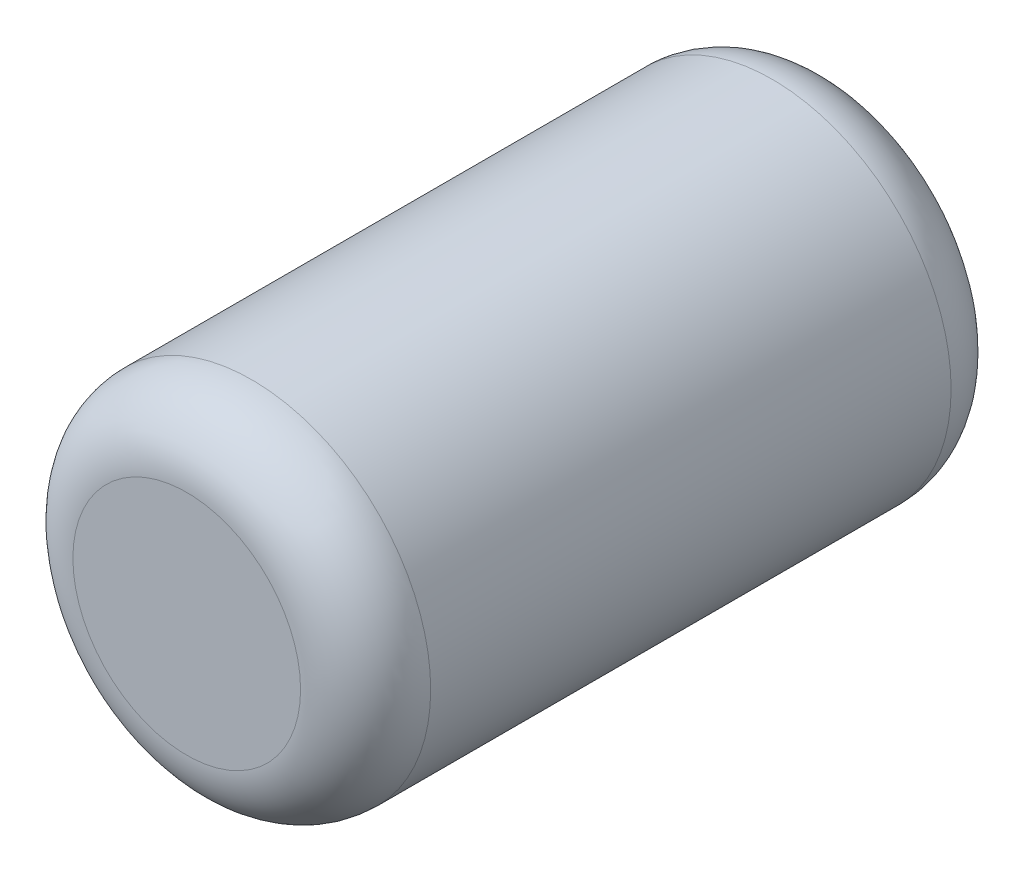
from build123d import *

# Parameters (mm, degrees)
SKETCH1_R           = 34.925
BOSS_EXTRUDE1_DEPTH = 127
FILLET2_R           = 12.7
FILLET3_R           = 12.7


with BuildPart() as part:
    # Sketch1 → Boss-Extrude1 (new body)
    with BuildSketch(Plane.XY):
        Circle(SKETCH1_R)
    extrude(amount=BOSS_EXTRUDE1_DEPTH)

    # Fillet2
    fillet2_edges = [part.edges().sort_by_distance(p)[0] for p in [
        (-34.925, 0, 127),
    ]]
    fillet(fillet2_edges, radius=FILLET2_R)

    # Fillet3
    fillet3_edges = [part.edges().sort_by_distance(p)[0] for p in [
        (-34.925, 0, 0),
    ]]
    fillet(fillet3_edges, radius=FILLET3_R)


solid = part.part
